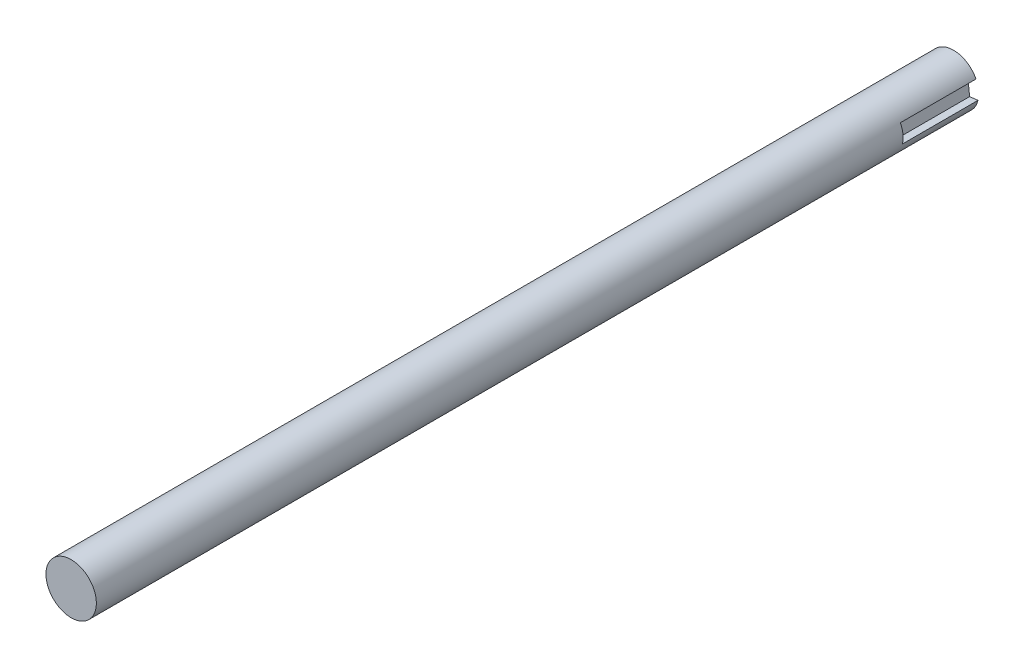
from build123d import *

# Parameters (mm, degrees)
SKETCH1_R                = 5
BOSS_EXTRUDE1_DEPTH      = 72
BOSS_EXTRUDE1_DEPTH_BACK = 103
CUT_EXTRUDE1_DEPTH       = 15


with BuildPart() as part:
    # Sketch1 → Boss-Extrude1 (new body, two sides)
    with BuildSketch(Plane.XY) as boss_extrude1_sk:
        Circle(SKETCH1_R)
    extrude(amount=BOSS_EXTRUDE1_DEPTH)
    extrude(boss_extrude1_sk.sketch, amount=-BOSS_EXTRUDE1_DEPTH_BACK)

    # Sketch2 → Cut-Extrude1 (cut)
    with BuildSketch(Plane(origin=(0, 0, -103), x_dir=(-1, 0, 0), z_dir=(0, 0, -1))):
        with BuildLine():
            Line((-4.855567152, -1.193091626), (-3.196182545, -1.381362864))
            Line((-3.196182545, -1.381362864), (-2.802213635, 2.090999416))
            Line((-2.802213635, 2.090999416), (-4.458066071, 2.263989158))
            ThreePointArc((-4.458066071, 2.263989158), (-4.967272173, 0.571145479), (-4.855567152, -1.193091626))
        make_face()
    extrude(amount=-CUT_EXTRUDE1_DEPTH, mode=Mode.SUBTRACT)


solid = part.part
